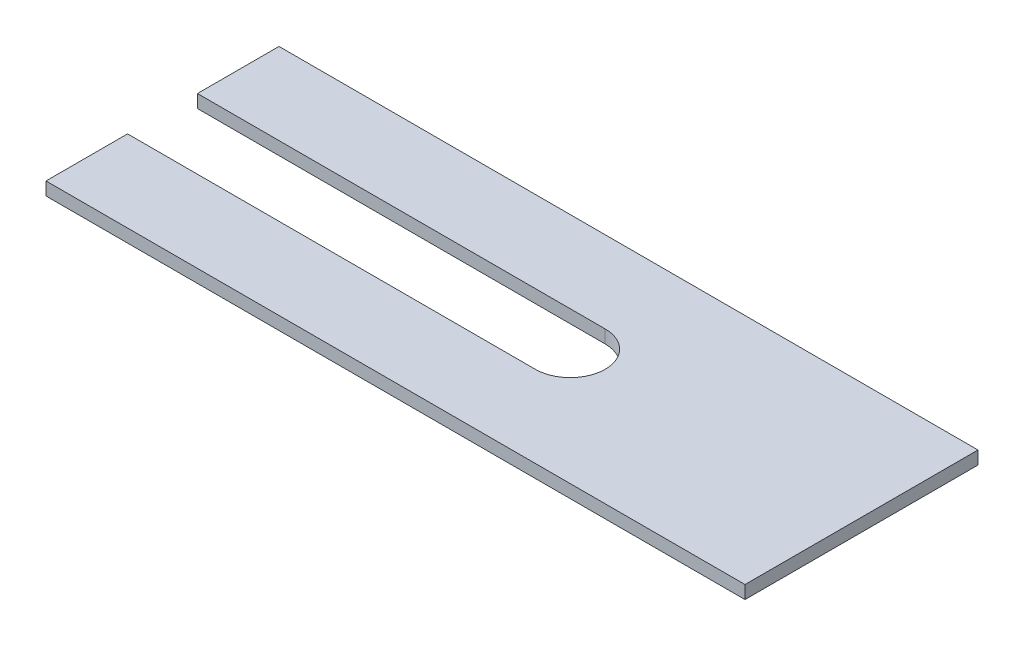
from build123d import *

# Parameters (mm, degrees)
BOSS_EXTRUDE1_DEPTH = 1.62
CHAMFER1_SIZE       = 0.5


with BuildPart() as part:
    # Sketch1 → Boss-Extrude1 (new body)
    with BuildSketch(Plane(origin=(0, 0, 0), x_dir=(1, 0, 0), z_dir=(0, 1, 0))):
        with BuildLine():
            ThreePointArc((17.5, 3), (20.5, 0), (17.5, -3))
            Line((17.5, -3), (-17.5, -3))
            Line((-17.5, -3), (-17.5, -10))
            Line((-17.5, -10), (42.5, -10))
            Line((42.5, -10), (42.5, 10))
            Line((42.5, 10), (-17.5, 10))
            Line((-17.5, 10), (-17.5, 3))
            Line((-17.5, 3), (17.5, 3))
        make_face()
    extrude(amount=BOSS_EXTRUDE1_DEPTH)

    # Chamfer1
    chamfer1_edges = [part.edges().sort_by_distance(p)[0] for p in [
        (-17.5, 0, -6.5),
        (12.5, 0, -10),
        (42.5, 0, 0),
        (12.5, 0, 10),
        (-17.5, 0, 6.5),
        (0, 0, 3),
        (20.5, 0, 0),
        (0, 0, -3),
    ]]
    chamfer(chamfer1_edges, length=CHAMFER1_SIZE)


solid = part.part
